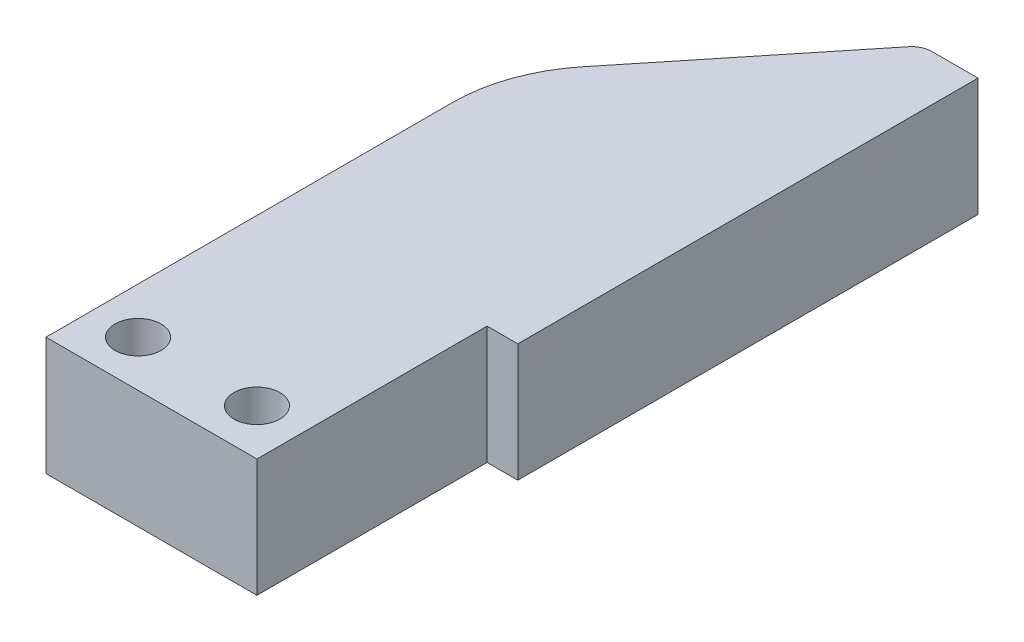
from build123d import *

# Parameters (mm, degrees)
SKETCH1_R           = 1.5
BOSS_EXTRUDE3_DEPTH = 3.85


with BuildPart() as part:
    # Sketch1 → Boss-Extrude3 (new body, symmetric)
    with BuildSketch(Plane(origin=(0, 0, 0), x_dir=(1, 0, 0), z_dir=(0, 1, 0))):
        with BuildLine():
            Line((-13.75, -15), (0, -15))
            Line((0, -15), (0, 0))
            Line((0, 0), (2, 0))
            Line((2, 0), (2, 30))
            Line((2, 30), (-1, 30))
            ThreePointArc((-1, 30), (-1.576352013, 29.869367868), (-2.040057994, 29.503003078))
            Line((-2.040057994, 29.503003078), (-11.530466398, 17.748937838))
            ThreePointArc((-11.530466398, 17.748937838), (-13.178803317, 14.798188939), (-13.75, 11.466872681))
            Line((-13.75, 11.466872681), (-13.75, -15))
        make_face()
        with Locations((-10.75, -12)):
            Circle(SKETCH1_R, mode=Mode.SUBTRACT)
        with Locations((-3, -12)):
            Circle(SKETCH1_R, mode=Mode.SUBTRACT)
    extrude(amount=BOSS_EXTRUDE3_DEPTH, both=True)


solid = part.part
